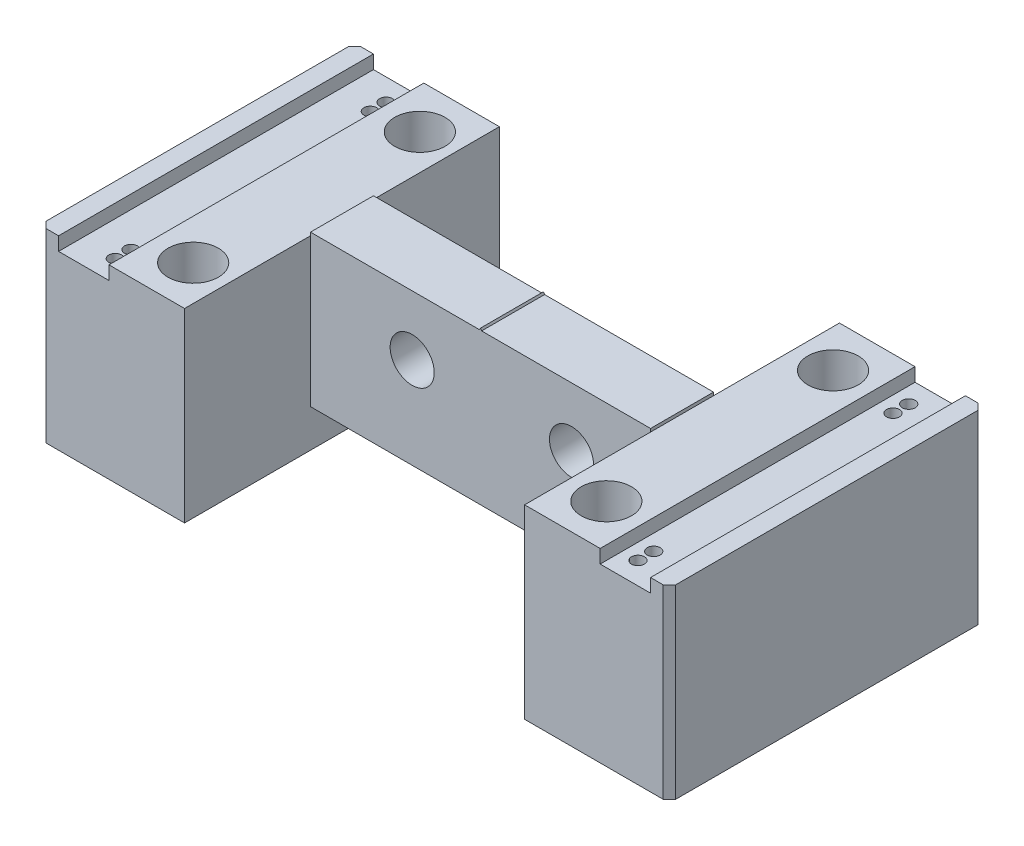
from build123d import *

# Parameters (mm, degrees)
BOSS_EXTRUDE1_DEPTH     = 50
SKETCH2_W               = 10
SKETCH2_H               = 30
BOSS_EXTRUDE2_DEPTH     = 54
BOSS_EXTRUDE4_DEPTH     = 10
BOSS_EXTRUDE5_DEPTH     = 50
SKETCH5_R               = 3.5
CUT_EXTRUDE1_DEPTH      = 54
SKETCH6_R               = 2.25
CUT_EXTRUDE2_DEPTH      = 30.5
SKETCH7_R               = 4
CUT_EXTRUDE3_DEPTH      = 10
M2_5_TAPPED_HOLE2_D     = 2.05
M2_5_TAPPED_HOLE2_DEPTH = 6.35
M2_5_TAPPED_HOLE2_TIP   = 0.615882135
CHAMFER1_SIZE           = 1
SKETCH14_W              = 54
SKETCH14_H              = 6
CUT_EXTRUDE4_DEPTH      = 10


with BuildPart() as part:
    # Sketch1 → Boss-Extrude1 (new body)
    with BuildSketch(Plane.XY):
        Polygon((6.013513514, 8.114864865), (9.013513514, 8.114864865), (9.013513514, -21.385135135), (-13.986486486, -21.385135135), (-13.986486486, 8.114864865), (-1.986486486, 8.114864865), (-1.986486486, 5.964864865), (6.013513514, 5.964864865), align=None)
    extrude(amount=BOSS_EXTRUDE1_DEPTH)

    # Sketch2 → Boss-Extrude2 (add)
    with BuildSketch(Plane.ZY.offset(13.986486486)):
        with Locations((25, -6.385135135)):
            Rectangle(SKETCH2_W, SKETCH2_H)
    extrude(amount=BOSS_EXTRUDE2_DEPTH)

    # Sketch3 → Boss-Extrude4 (add)
    with BuildSketch(Plane(origin=(0, 0, 20), x_dir=(-1, 0, 0), z_dir=(0, 0, -1))):
        Polygon((40.811486486, 8.614864865), (40.986486486, 8.917973756), (41.161486486, 8.614864865), align=None)
    extrude(amount=-BOSS_EXTRUDE4_DEPTH)

    # Sketch4 → Boss-Extrude5 (add)
    with BuildSketch(Plane(origin=(0, 0, 0), x_dir=(-1, 0, 0), z_dir=(0, 0, -1))):
        Polygon((67.986486486, 8.114864865), (79.986486486, 8.114864865), (79.986486486, 5.964864865), (87.986486486, 5.964864865), (87.986486486, 8.114864865), (90.986486486, 8.114864865), (90.986486486, -21.385135135), (67.986486486, -21.385135135), align=None)
    extrude(amount=-BOSS_EXTRUDE5_DEPTH)

    # Sketch5 → Cut-Extrude1 (cut)
    with BuildSketch(Plane(origin=(0, 0, 20), x_dir=(-1, 0, 0), z_dir=(0, 0, -1))):
        with Locations((26.537216594, -0.885135135)):
            Circle(SKETCH5_R)
        with Locations((51.838124653, -0.885135135)):
            Circle(SKETCH5_R)
    extrude(amount=-CUT_EXTRUDE1_DEPTH, mode=Mode.SUBTRACT)

    # Sketch6 → Cut-Extrude2 (cut, through all)
    with BuildSketch(Plane(origin=(0, 8.114864865, 0), x_dir=(1, 0, 0), z_dir=(0, 1, 0))):
        with Locations((-7.981926448, -7.026366578)):
            Circle(SKETCH6_R)
        with Locations((-7.981926448, -43.021631087)):
            Circle(SKETCH6_R)
        with Locations((-73.593710074, -43.021631087)):
            Circle(SKETCH6_R)
        with Locations((-73.593710074, -7.026366578)):
            Circle(SKETCH6_R)
    extrude(amount=-CUT_EXTRUDE2_DEPTH, mode=Mode.SUBTRACT)

    # Sketch7 → Cut-Extrude3 (cut)
    with BuildSketch(Plane(origin=(0, 8.114864865, 0), x_dir=(1, 0, 0), z_dir=(0, 1, 0))):
        with Locations((-7.981926448, -43.021631087)):
            Circle(SKETCH7_R)
        with Locations((-7.981926448, -7.026366578)):
            Circle(SKETCH7_R)
        with Locations((-73.593710074, -43.021631087)):
            Circle(SKETCH7_R)
        with Locations((-73.593710074, -7.026366578)):
            Circle(SKETCH7_R)
    extrude(amount=-CUT_EXTRUDE3_DEPTH, mode=Mode.SUBTRACT)

    # M2.5 Tapped Hole2
    with Locations(Plane(origin=(0, 5.964864865, 0), x_dir=(1, 0, 0), z_dir=(0, 1, 0))):
        with Locations((0.513513514, -46.5), (0.513513514, -3.5), (-82.486486486, -46.5), (-82.486486486, -3.5), (0.513513514, -44), (0.513513514, -6), (-82.486486486, -44), (-82.486486486, -6)):
            Hole(M2_5_TAPPED_HOLE2_D / 2, depth=M2_5_TAPPED_HOLE2_DEPTH)
            with Locations((0, 0, -(M2_5_TAPPED_HOLE2_DEPTH + M2_5_TAPPED_HOLE2_TIP / 2))):  # 118° drill point
                Cone(0, M2_5_TAPPED_HOLE2_D / 2, M2_5_TAPPED_HOLE2_TIP, mode=Mode.SUBTRACT)

    # Chamfer1
    chamfer1_edges = [part.edges().sort_by_distance(p)[0] for p in [
        (9.013513514, -6.635135135, 50),
        (-90.986486486, -6.635135135, 50),
        (-90.986486486, -6.635135135, 0),
        (9.013513514, -6.635135135, 0),
    ]]
    chamfer(chamfer1_edges, length=CHAMFER1_SIZE)

    # Sketch14 → Cut-Extrude4 (cut)
    with BuildSketch(Plane(origin=(0, 0, 20), x_dir=(-1, 0, 0), z_dir=(0, 0, -1))):
        with Locations((40.986486486, -18.385135135)):
            Rectangle(SKETCH14_W, SKETCH14_H)
    extrude(amount=-CUT_EXTRUDE4_DEPTH, mode=Mode.SUBTRACT)


solid = part.part
